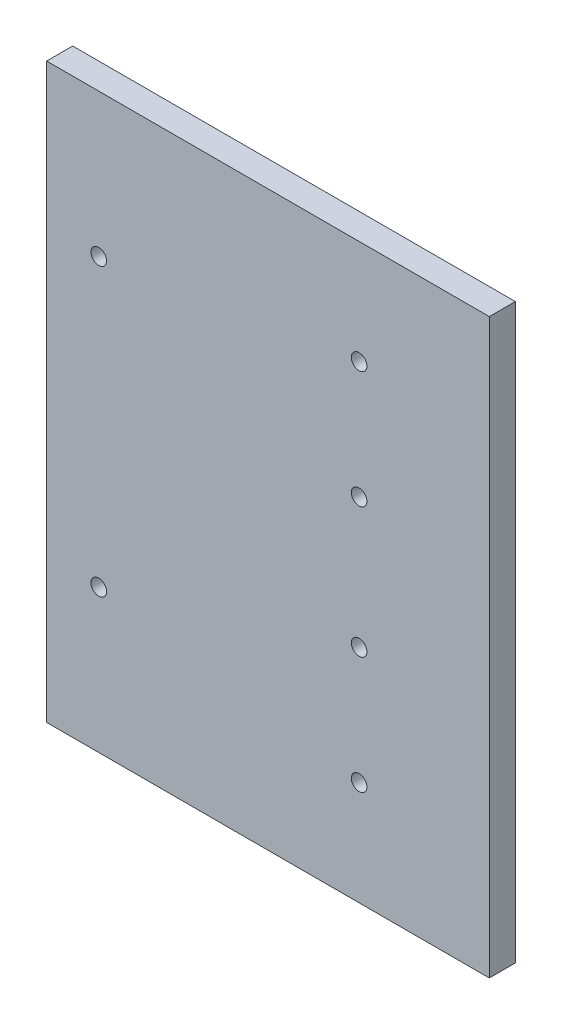
from build123d import *

# Parameters (mm, degrees)
SKETCH1_W           = 170
SKETCH1_H           = 110
BOSS_EXTRUDE1_DEPTH = 5
SKETCH2_R           = 1.5
CUT_EXTRUDE1_DEPTH  = 6
SKETCH3_R           = 1.5
CUT_EXTRUDE2_DEPTH  = 6
SKETCH4_W           = 40.789310726
SKETCH4_H           = 120.699967799
CUT_EXTRUDE3_DEPTH  = 86


with BuildPart() as part:
    # Sketch1 → Boss-Extrude1 (new body)
    with BuildSketch(Plane.XY):
        Rectangle(SKETCH1_W, SKETCH1_H)
    extrude(amount=BOSS_EXTRUDE1_DEPTH)

    # Sketch2 → Cut-Extrude1 (cut, through all)
    with BuildSketch(Plane.XY.offset(5)):
        with Locations((-75, 27.5)):
            Circle(SKETCH2_R)
        with Locations((-75, -27.5)):
            Circle(SKETCH2_R)
        with Locations((75, -27.5)):
            Circle(SKETCH2_R)
        with Locations((75, 27.5)):
            Circle(SKETCH2_R)
    extrude(amount=-CUT_EXTRUDE1_DEPTH, mode=Mode.SUBTRACT)

    # Sketch3 → Cut-Extrude2 (cut, through all)
    with BuildSketch(Plane.XY.offset(5)):
        with Locations((-25, 35)):
            Circle(SKETCH3_R)
        with Locations((-25, 12.5)):
            Circle(SKETCH3_R)
        with Locations((-25, -12.5)):
            Circle(SKETCH3_R)
        with Locations((-25, -35)):
            Circle(SKETCH3_R)
        with Locations((25, -35)):
            Circle(SKETCH3_R)
        with Locations((25, -12.5)):
            Circle(SKETCH3_R)
        with Locations((25, 12.5)):
            Circle(SKETCH3_R)
        with Locations((25, 35)):
            Circle(SKETCH3_R)
    extrude(amount=-CUT_EXTRUDE2_DEPTH, mode=Mode.SUBTRACT)

    # Sketch4 → Cut-Extrude3 (cut, through all)
    with BuildSketch(Plane(origin=(0, 0, 0), x_dir=(0, 0, -1), z_dir=(1, 0, 0))):
        with Locations((-5.456845945, -1.288881565)):
            Rectangle(SKETCH4_W, SKETCH4_H)
    extrude(amount=CUT_EXTRUDE3_DEPTH, mode=Mode.SUBTRACT)


solid = part.part
